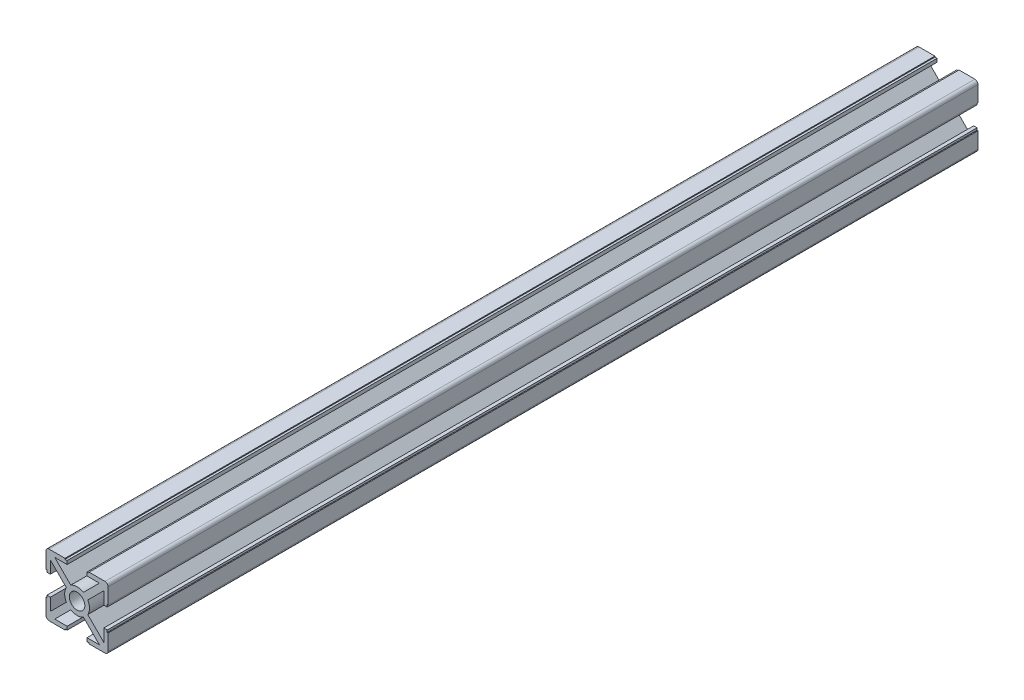
from build123d import *

# Parameters (mm, degrees)
SKETCH1_R           = 2.5
BOSS_EXTRUDE1_DEPTH = 280


with BuildPart() as part:
    # Sketch1 → Boss-Extrude1 (new body)
    with BuildSketch(Plane.XY):
        with BuildLine():
            Line((-9.707106781, -3.2), (-8.6, -3.2))
            Line((-8.6, -3.2), (-8.6, -7.185786438))
            Line((-8.6, -7.185786438), (-3.445719569, -2.031506006))
            ThreePointArc((-3.445719569, -2.031506006), (-4, 0), (-3.445719569, 2.031506006))
            Line((-3.445719569, 2.031506006), (-8.6, 7.185786438))
            Line((-8.6, 7.185786438), (-8.6, 3.2))
            Line((-8.6, 3.2), (-9.707106781, 3.2))
            Line((-9.707106781, 3.2), (-9.707106781, 3.877544562))
            Line((-9.707106781, 3.877544562), (-10, 3.877544562))
            Line((-10, 3.877544562), (-10, 9))
            ThreePointArc((-10, 9), (-9.707106781, 9.707106781), (-9, 10))
            Line((-9, 10), (-3.877544562, 10))
            Line((-3.877544562, 10), (-3.877544562, 9.707106781))
            Line((-3.877544562, 9.707106781), (-3.2, 9.707106781))
            Line((-3.2, 9.707106781), (-3.2, 8.6))
            Line((-3.2, 8.6), (-7.185786438, 8.6))
            Line((-7.185786438, 8.6), (-2.031506006, 3.445719569))
            ThreePointArc((-2.031506006, 3.445719569), (0, 4), (2.031506006, 3.445719569))
            Line((2.031506006, 3.445719569), (7.185786438, 8.6))
            Line((7.185786438, 8.6), (3.2, 8.6))
            Line((3.2, 8.6), (3.2, 9.707106781))
            Line((3.2, 9.707106781), (3.877544562, 9.707106781))
            Line((3.877544562, 9.707106781), (3.877544562, 10))
            Line((3.877544562, 10), (9, 10))
            ThreePointArc((9, 10), (9.707106781, 9.707106781), (10, 9))
            Line((10, 9), (10, 3.877544562))
            Line((10, 3.877544562), (9.707106781, 3.877544562))
            Line((9.707106781, 3.877544562), (9.707106781, 3.2))
            Line((9.707106781, 3.2), (8.6, 3.2))
            Line((8.6, 3.2), (8.6, 7.185786438))
            Line((8.6, 7.185786438), (3.445719569, 2.031506006))
            ThreePointArc((3.445719569, 2.031506006), (4, 0), (3.445719569, -2.031506006))
            Line((3.445719569, -2.031506006), (8.6, -7.185786438))
            Line((8.6, -7.185786438), (8.6, -3.2))
            Line((8.6, -3.2), (9.707106781, -3.2))
            Line((9.707106781, -3.2), (9.707106781, -3.877544562))
            Line((9.707106781, -3.877544562), (10, -3.877544562))
            Line((10, -3.877544562), (10, -9))
            ThreePointArc((10, -9), (9.707106781, -9.707106781), (9, -10))
            Line((9, -10), (3.877544562, -10))
            Line((3.877544562, -10), (3.877544562, -9.707106781))
            Line((3.877544562, -9.707106781), (3.2, -9.707106781))
            Line((3.2, -9.707106781), (3.2, -8.6))
            Line((3.2, -8.6), (7.185786438, -8.6))
            Line((7.185786438, -8.6), (2.031506006, -3.445719569))
            ThreePointArc((2.031506006, -3.445719569), (0, -4), (-2.031506006, -3.445719569))
            Line((-2.031506006, -3.445719569), (-7.185786438, -8.6))
            Line((-7.185786438, -8.6), (-3.2, -8.6))
            Line((-3.2, -8.6), (-3.2, -9.707106781))
            Line((-3.2, -9.707106781), (-3.877544562, -9.707106781))
            Line((-3.877544562, -9.707106781), (-3.877544562, -10))
            Line((-3.877544562, -10), (-9, -10))
            ThreePointArc((-9, -10), (-9.707106781, -9.707106781), (-10, -9))
            Line((-10, -9), (-10, -3.877544562))
            Line((-10, -3.877544562), (-9.707106781, -3.877544562))
            Line((-9.707106781, -3.877544562), (-9.707106781, -3.2))
        make_face()
        Circle(SKETCH1_R, mode=Mode.SUBTRACT)
    extrude(amount=BOSS_EXTRUDE1_DEPTH)


solid = part.part
